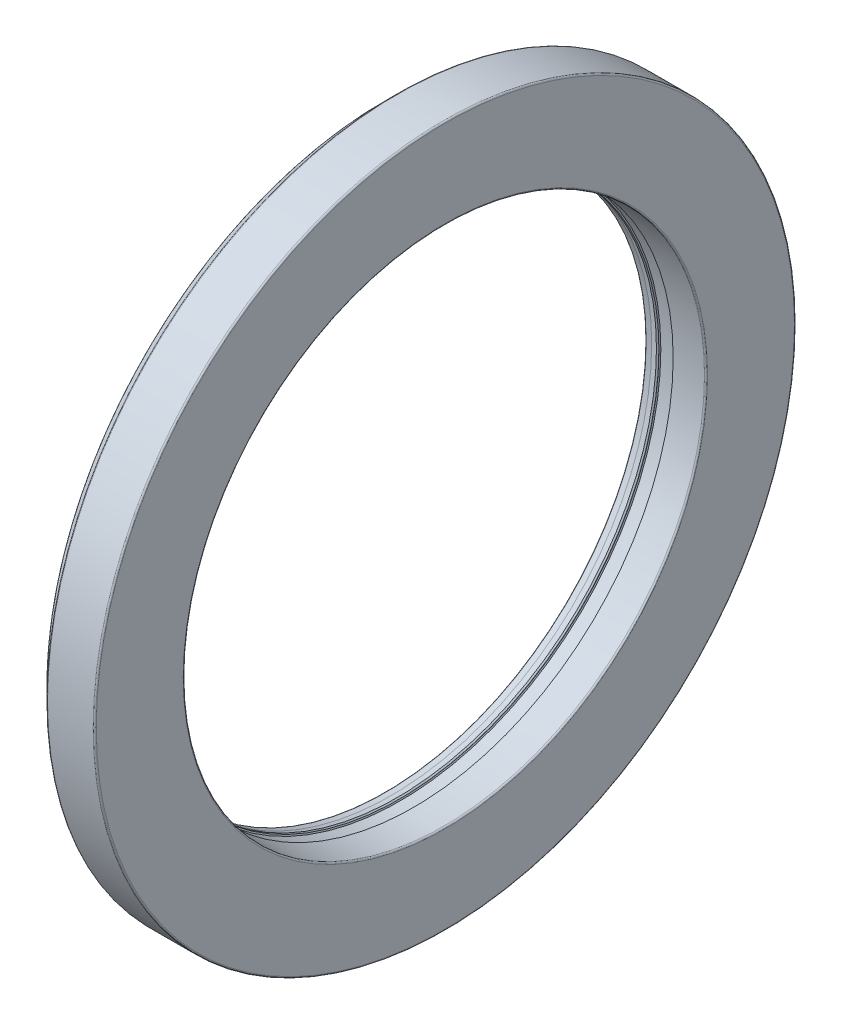
from build123d import *


with BuildPart() as part:
    # Schizzo1 → Rivoluzione1 (revolve)
    with BuildSketch(Plane.XY):
        with BuildLine():
            Line((-7.985355339, 11.100431099), (-7.600431099, 11.485355339))
            ThreePointArc((-7.600431099, 11.485355339), (-7.584209931, 11.496193977), (-7.56507576, 11.5))
            Line((-7.56507576, 11.5), (-6.068254383, 11.5))
            ThreePointArc((-6.068254383, 11.5), (-6.032899044, 11.485355339), (-6.018254383, 11.45))
            Line((-6.018254383, 11.45), (-6.018254383, 8.598033841))
            ThreePointArc((-6.018254383, 8.598033841), (-6.032197211, 8.563394552), (-6.066249597, 8.548074049))
            Line((-6.066249597, 8.548074049), (-7.054328206, 8.508424441))
            Line((-7.054328206, 8.508424441), (-7.075459918, 8.55))
            Line((-7.075459918, 8.55), (-7.499757992, 8.55))
            Line((-7.499757992, 8.55), (-7.520889703, 8.508424441))
            Line((-7.520889703, 8.508424441), (-7.542021415, 8.55))
            Line((-7.542021415, 8.55), (-7.562465262, 8.55))
            Line((-7.562465262, 8.55), (-7.604040821, 8.51))
            Line((-7.604040821, 8.51), (-7.8, 8.55))
            Line((-7.8, 8.55), (-7.98, 8.55))
            ThreePointArc((-7.98, 8.55), (-7.994142136, 8.555857864), (-8, 8.57))
            Line((-8, 8.57), (-8, 8.854372719))
            ThreePointArc((-8, 8.854372719), (-7.987408484, 8.887548092), (-7.955975787, 8.904014335))
            Line((-7.955975787, 8.904014335), (-6.789396951, 9.044445434))
            ThreePointArc((-6.789396951, 9.044445434), (-6.757964254, 9.060911677), (-6.745372738, 9.094087049))
            Line((-6.745372738, 9.094087049), (-6.745372738, 9.316782125))
            ThreePointArc((-6.745372738, 9.316782125), (-6.760017398, 9.352137464), (-6.795372738, 9.366782125))
            Line((-6.795372738, 9.366782125), (-7.08286255, 9.366782125))
            ThreePointArc((-7.08286255, 9.366782125), (-7.118217889, 9.352137464), (-7.13286255, 9.316782125))
            Line((-7.13286255, 9.316782125), (-7.13286255, 9.292845201))
            ThreePointArc((-7.13286255, 9.292845201), (-7.138720415, 9.278703065), (-7.15286255, 9.272845201))
            Line((-7.15286255, 9.272845201), (-7.95, 9.272845201))
            ThreePointArc((-7.95, 9.272845201), (-7.985355339, 9.287489862), (-8, 9.322845201))
            Line((-8, 9.322845201), (-8, 11.06507576))
            ThreePointArc((-8, 11.06507576), (-7.996193977, 11.084209931), (-7.985355339, 11.100431099))
        make_face()
    revolve(axis=Axis((0, 0, 0), (-1, 0, 0)))


solid = part.part
